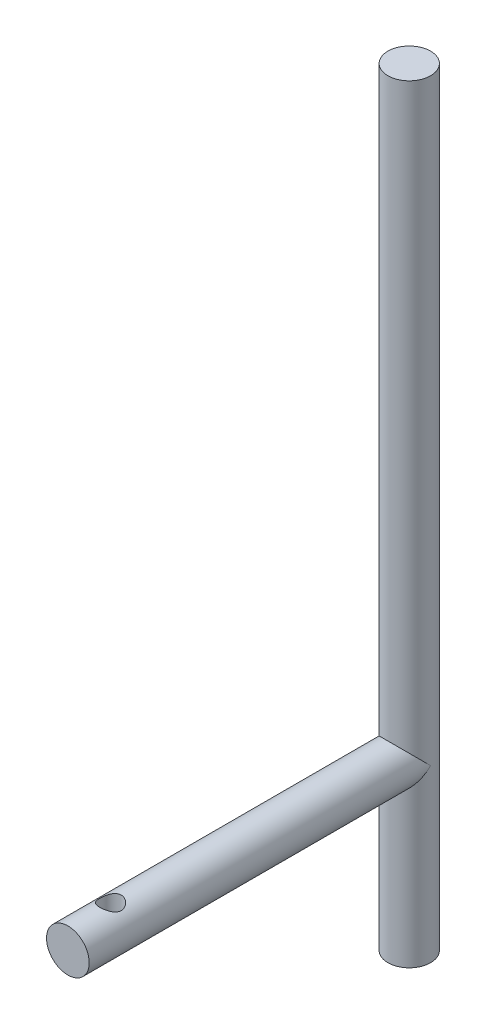
from build123d import *

# Parameters (mm, degrees)
SKETCH1_R           = 3.175
BOSS_EXTRUDE1_DEPTH = 114.3
SKETCH2_R           = 3.175
BOSS_EXTRUDE2_DEPTH = 50.8
SKETCH3_R           = 1.5875
CUT_EXTRUDE1_DEPTH  = 115.3


with BuildPart() as part:
    # Sketch1 → Boss-Extrude1 (new body)
    with BuildSketch(Plane(origin=(0, 0, 0), x_dir=(1, 0, 0), z_dir=(0, 1, 0))):
        Circle(SKETCH1_R)
    extrude(amount=BOSS_EXTRUDE1_DEPTH)

    # Sketch2 → Boss-Extrude2 (add)
    with BuildSketch(Plane.XY):
        with Locations((0, 25.4)):
            Circle(SKETCH2_R)
    extrude(amount=BOSS_EXTRUDE2_DEPTH)

    # Sketch3 → Cut-Extrude1 (cut, through all)
    with BuildSketch(Plane(origin=(0, 0, 0), x_dir=(1, 0, 0), z_dir=(0, 1, 0))):
        with Locations((0, -44.45)):
            Circle(SKETCH3_R)
    extrude(amount=CUT_EXTRUDE1_DEPTH, mode=Mode.SUBTRACT)


solid = part.part
